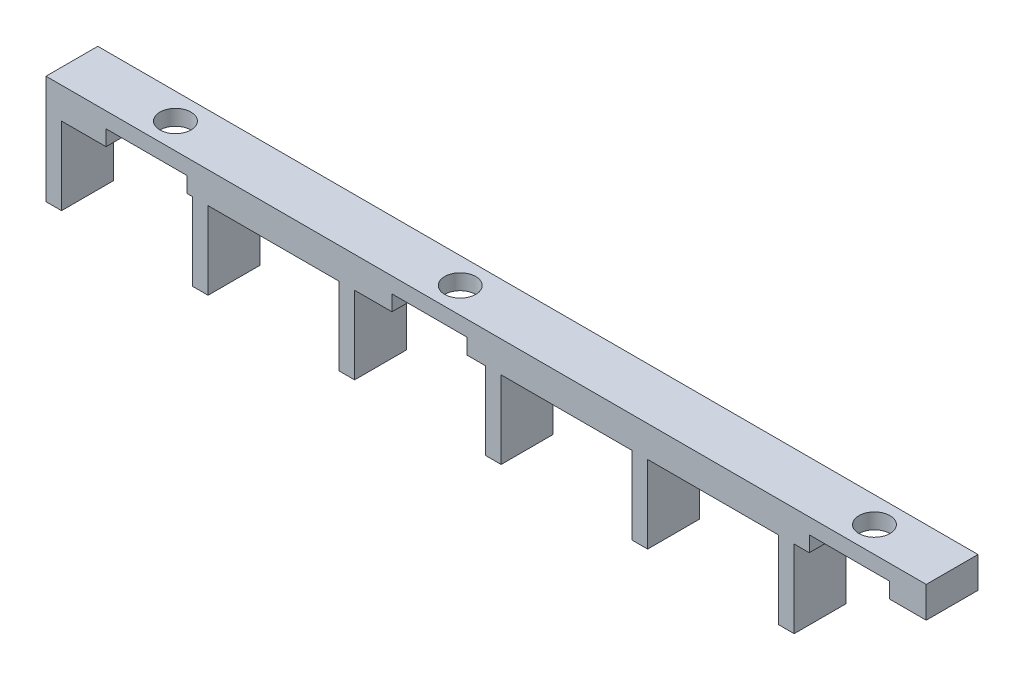
from build123d import *

# Parameters (mm, degrees)
SKETCH1_W           = 170
SKETCH1_H           = 10
BOSS_EXTRUDE1_DEPTH = 6
SKETCH3_W           = 3
SKETCH3_H           = 10
BOSS_EXTRUDE2_DEPTH = 15
LPATTERN1_COUNT     = 6
LPATTERN1_PITCH     = 28.3
SKETCH5_R           = 3
SKETCH5_R_2         = 1.8
CUT_EXTRUDE1_DEPTH  = 10
SKETCH7_W           = 15.610569604
SKETCH7_H           = 29.423295864
SKETCH7_W_2         = 14.543842925
SKETCH7_H_2         = 20.261696827
SKETCH7_W_3         = 15.463066773
SKETCH7_H_3         = 26.876388592
CUT_EXTRUDE3_DEPTH  = 3


with BuildPart() as part:
    # Sketch1 → Boss-Extrude1 (new body)
    with BuildSketch(Plane(origin=(0, 0, 0), x_dir=(1, 0, 0), z_dir=(0, 1, 0))):
        with Locations((-215, 0)):
            Rectangle(SKETCH1_W, SKETCH1_H)
    extrude(amount=BOSS_EXTRUDE1_DEPTH)

    # Sketch3 → Boss-Extrude2 (add)
    with BuildSketch(Plane.XZ):
        with Locations((-298.5, 0)):
            Rectangle(SKETCH3_W, SKETCH3_H)
    boss_extrude2 = extrude(amount=BOSS_EXTRUDE2_DEPTH)

    # LPattern1: Boss-Extrude2 ×6
    with Locations(*[(i * LPATTERN1_PITCH, 0, 0) for i in range(1, LPATTERN1_COUNT)]):
        add(boss_extrude2)

    # Sketch5 → Cut-Extrude1 (cut)
    with BuildSketch(Plane(origin=(0, 6, 0), x_dir=(1, 0, 0), z_dir=(0, 1, 0))):
        with Locations((-225, 0)):
            Circle(SKETCH5_R)
        with Locations((225, 0)):
            Circle(SKETCH5_R_2)
        with Locations((165, 0)):
            Circle(SKETCH5_R_2)
        with Locations((-280, 0)):
            Circle(SKETCH5_R)
        with Locations((-145, 0)):
            Circle(SKETCH5_R)
    extrude(amount=-CUT_EXTRUDE1_DEPTH, mode=Mode.SUBTRACT)

    # Sketch7 → Cut-Extrude3 (cut)
    with BuildSketch(Plane.XZ):
        with Locations((-280.60295859, 0.084727736)):
            Rectangle(SKETCH7_W, SKETCH7_H)
        with Locations((-225.915608204, -0.229636086)):
            Rectangle(SKETCH7_W_2, SKETCH7_H_2)
        with Locations((-144.85630026, -0.160459025)):
            Rectangle(SKETCH7_W_3, SKETCH7_H_3)
    extrude(amount=-CUT_EXTRUDE3_DEPTH, mode=Mode.SUBTRACT)


solid = part.part
